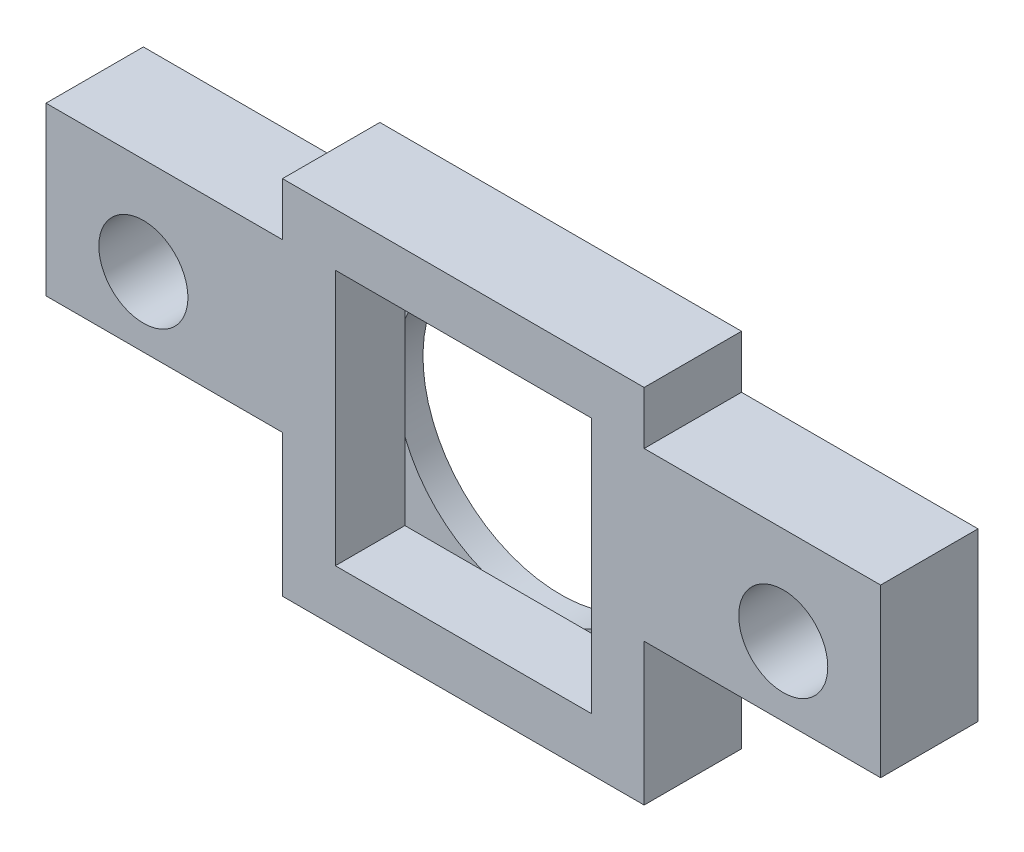
from build123d import *

# Parameters (mm, degrees)
SKETCH_1_W      = 13
SKETCH_1_H      = 13
SKETCH_1_R      = 4.95
EXTRUDE_1_DEPTH = 1
SKETCH_2_W      = 13
SKETCH_2_H      = 13
SKETCH_2_W_2    = 9.2
SKETCH_2_H_2    = 9.2
EXTRUDE_2_DEPTH = 2.5
SKETCH_3_W      = 8.5
SKETCH_3_H      = 6
SKETCH_3_R      = 1.6
EXTRUDE_3_DEPTH = 3.5


with BuildPart() as part:
    # 草图1 → 凸台-拉伸1 (new body)
    with BuildSketch(Plane.XY):
        with Locations((-0.565783989, 1.095956893)):
            Rectangle(SKETCH_1_W, SKETCH_1_H)
        with Locations((-0.565783989, 1.095956893)):
            Circle(SKETCH_1_R, mode=Mode.SUBTRACT)
    extrude(amount=EXTRUDE_1_DEPTH)

    # 草图2 → 凸台-拉伸2 (add)
    with BuildSketch(Plane.XY.offset(1)):
        with Locations((-0.565783989, 1.095956893)):
            Rectangle(SKETCH_2_W, SKETCH_2_H)
        with Locations((-0.565783989, 1.095956893)):
            Rectangle(SKETCH_2_W_2, SKETCH_2_H_2, mode=Mode.SUBTRACT)
    extrude(amount=EXTRUDE_2_DEPTH)

    # 草图3 → 凸台-拉伸3 (add)
    with BuildSketch(Plane.XY.offset(3.5)):
        with Locations((10.184216011, 2.695956893)):
            Rectangle(SKETCH_3_W, SKETCH_3_H)
        with Locations((10.934216011, 2.195956893)):
            Circle(SKETCH_3_R, mode=Mode.SUBTRACT)
        with Locations((-11.315783989, 2.695956893)):
            Rectangle(SKETCH_3_W, SKETCH_3_H)
        with Locations((-12.065783989, 2.195956893)):
            Circle(SKETCH_3_R, mode=Mode.SUBTRACT)
    extrude(amount=-EXTRUDE_3_DEPTH)


solid = part.part
